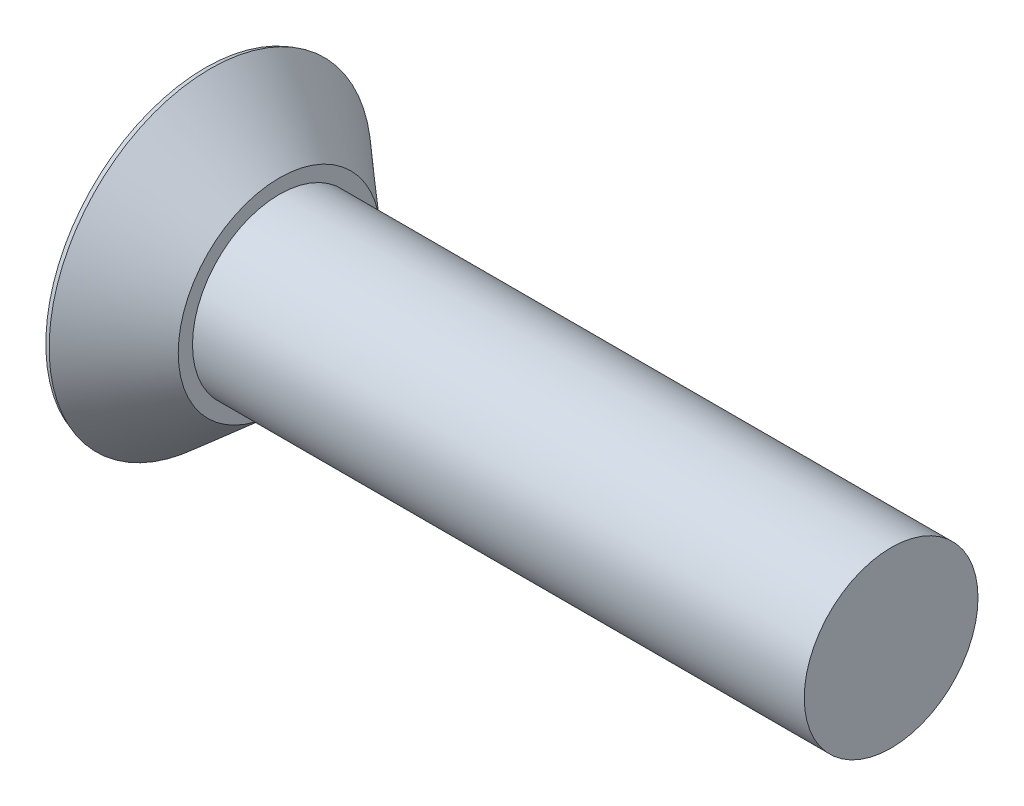
from build123d import *

# Parameters (mm, degrees)
CUT_EXTRUDE1_REACH = 22.129
CIRPATTERN1_COUNT  = 4
DRAFT1_ANGLE       = 5
CHAMFER1_SIZE      = 0.183896
CHAMFER1_SIZE2     = 0.168435197


with BuildPart() as part:
    # Sketch2 → Revolve1 (revolve)
    with BuildSketch(Plane.XY, mode=Mode.PRIVATE) as revolve1_sk:
        Polygon((-9.525, 0), (9.525, 0), (9.525, 2.413), (-7.4676, 2.413), (-7.4676, 2.808929466), (-9.525, 4.5974), align=None)
    revolve(revolve1_sk.sketch.rotate(Axis((-9.525, 0, 0), (1, 0, 0)), 180), axis=Axis((-9.525, 0, 0), (1, 0, 0)))

    # Cut-Extrude1: up to this cone (the profile starts inside it)
    cut_extrude1_end = Plane(origin=(-9.525, 0, 0), z_dir=(-1, 0, 0)).offset(-2.952835668) * Cone(1e-06, 24.469290226, 28.148697423, align=(Align.CENTER, Align.CENTER, Align.MIN), mode=Mode.PRIVATE)
    # Sketch3 → Cut-Extrude1 (cut, up to the surface)
    with BuildSketch(Plane.ZY.offset(9.525), mode=Mode.PRIVATE) as cut_extrude1_sk1:
        with BuildLine():
            Line((0, 0), (3.064933333, 0))
            ThreePointArc((3.064933333, 0), (3.04941298, 0.308053268), (3.003009105, 0.612986667))
            Line((3.003009105, 0.612986667), (1.807997886, 0.612986667))
            Line((1.807997886, 0.612986667), (0.962997349, 0.962997349))
            Line((0.962997349, 0.962997349), (0.612986667, 1.807997886))
            Line((0.612986667, 1.807997886), (0.612986667, 3.003009105))
            ThreePointArc((0.612986667, 3.003009105), (0.308053268, 3.04941298), (0, 3.064933333))
            Line((0, 3.064933333), (0, 0))
        make_face()
    cut_extrude1_tool1 = extrude(cut_extrude1_sk1.sketch, amount=-CUT_EXTRUDE1_REACH, mode=Mode.PRIVATE) & cut_extrude1_end
    cut_extrude1 = cut_extrude1_tool1.solids().sort_by_distance((-9.525, 1.532467, 0.043345))[0]
    add(cut_extrude1, mode=Mode.SUBTRACT)

    # CirPattern1: Cut-Extrude1 ×4 about axis
    cirpattern1_axis = Axis((0, 0, 0), (1, 0, 0))
    for i in range(1, CIRPATTERN1_COUNT):
        add(cut_extrude1.rotate(cirpattern1_axis, i * 360 / CIRPATTERN1_COUNT), mode=Mode.SUBTRACT)

    # Draft1
    draft1_faces = [part.faces().sort_by_distance(p)[0] for p in [
        (-9.272207982, 0.612986667, -2.036620878),
        (-8.957922731, 0.804804583, -1.344908471),
        (-8.957922731, 1.344908471, -0.804804583),
        (-9.272207982, 2.036620878, -0.612986667),
        (-9.272207982, 2.036620878, 0.612986667),
        (-8.957922731, 1.344908471, 0.804804583),
        (-8.957922731, 0.804804583, 1.344908471),
        (-9.272207982, 0.612986667, 2.036620878),
        (-9.272207982, -0.612986667, 2.036620878),
        (-8.957922731, -0.804804583, 1.344908471),
        (-8.957922731, -1.344908471, 0.804804583),
        (-9.272207982, -2.036620878, 0.612986667),
        (-9.272207982, -2.036620878, -0.612986667),
        (-8.957922731, -1.344908471, -0.804804583),
        (-8.957922731, -0.804804583, -1.344908471),
        (-9.272207982, -0.612986667, -2.036620878),
    ]]
    draft(draft1_faces, Plane(origin=(-9.525, 0, 0), x_dir=(0, -1, 0), z_dir=(-1, 0, 0)), DRAFT1_ANGLE)

    # Chamfer1
    chamfer1_edges = [part.edges().sort_by_distance(p)[0] for p in [
        (-9.525, 4.5974, 0),
    ]]
    chamfer1_side = [part.faces().sort_by_distance(p)[0] for p in [
        (-8.4963, 3.703164733, 0),
    ]]
    chamfer(chamfer1_edges, length=CHAMFER1_SIZE, length2=CHAMFER1_SIZE2, reference=chamfer1_side[0])


solid = part.part
